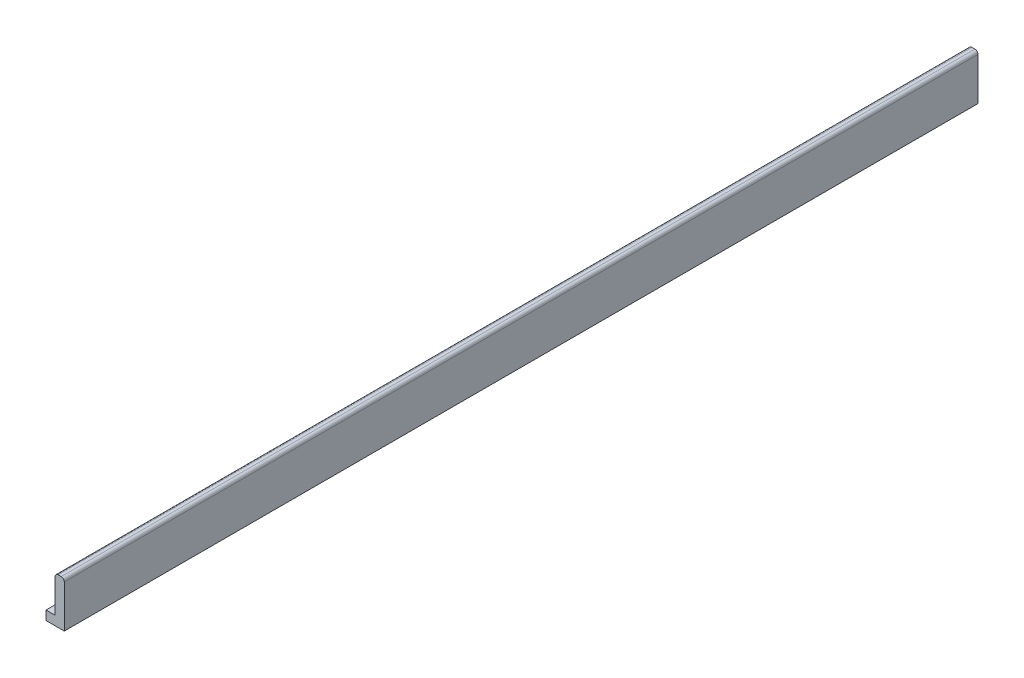
from build123d import *

# Parameters (mm, degrees)
BOSS_EXTRUDE3_DEPTH = 3000
FILLET1_R           = 10


with BuildPart() as part:
    # Sketch1 → Boss-Extrude3 (new body)
    with BuildSketch(Plane.XY):
        Polygon((0, -75), (0, 75), (-30, 75), (-30, -45), (-60, -45), (-60, -75), align=None)
    extrude(amount=BOSS_EXTRUDE3_DEPTH)

    # Fillet1
    fillet1_edges = [part.edges().sort_by_distance(p)[0] for p in [
        (-30, 75, 1500),
        (0, 75, 1500),
    ]]
    fillet(fillet1_edges, radius=FILLET1_R)


solid = part.part
